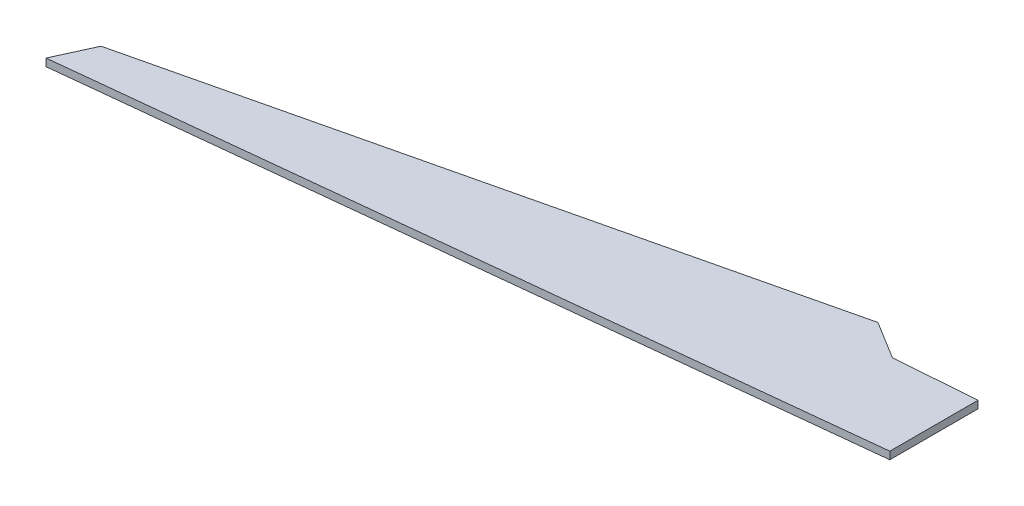
from build123d import *

# Parameters (mm, degrees)
BOSS_EXTRUDE1_DEPTH = 75


with BuildPart() as part:
    # Sketch1 → Boss-Extrude1 (new body)
    with BuildSketch(Plane(origin=(0, 0, 0), x_dir=(1, 0, 0), z_dir=(0, 1, 0))):
        Polygon((0, 0), (-7537.08161653, -805.481660729), (-7364.304947929, -426.783515384), (-1074.559415934, 1068.317197863), (-695.657742481, 834.953700601), (102.114472392, 894.615188825), (102.114472392, 10.912888966), align=None)
    extrude(amount=BOSS_EXTRUDE1_DEPTH)


solid = part.part
